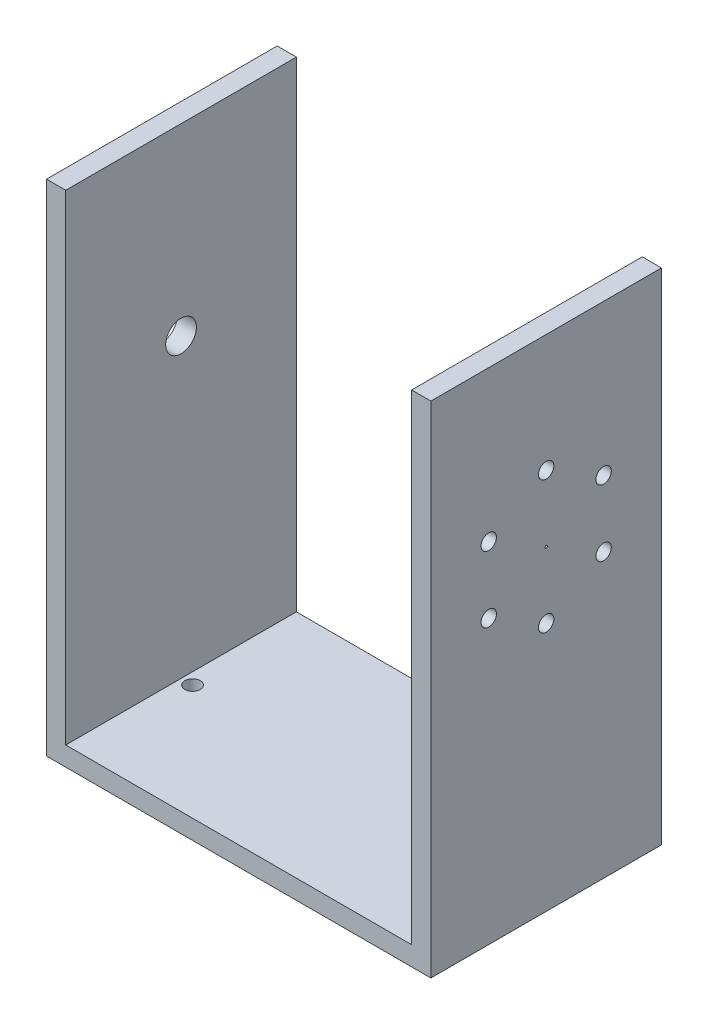
from build123d import *

# Parameters (mm, degrees)
EXTRUDE_1_DEPTH     = 60
SKETCH_2_R          = 2
CUT_EXTRUDE_1_DEPTH = 6
SKETCH_3_R          = 2
SKETCH_3_R_2        = 0.32384185
CUT_EXTRUDE_2_DEPTH = 10
SKETCH_5_R          = 4
SKETCH_5_R_2        = 0.32384185
CUT_EXTRUDE_4_DEPTH = 6


with BuildPart() as part:
    # 草图1 → 凸台-拉伸1 (new body)
    with BuildSketch(Plane.XY):
        Polygon((95, -81.837278389), (95, 48.162721611), (90, 48.162721611), (90, -76.837278389), (0, -76.837278389), (0, 48.162721611), (-5, 48.162721611), (-5, -81.837278389), align=None)
    extrude(amount=EXTRUDE_1_DEPTH)

    # 草图2 → 切除-拉伸1 (cut, through all)
    with BuildSketch(Plane(origin=(0, -76.837278389, 0), x_dir=(1, 0, 0), z_dir=(0, 1, 0))):
        with Locations((3, -30)):
            Circle(SKETCH_2_R)
        with Locations((87, -30)):
            Circle(SKETCH_2_R)
    extrude(amount=-CUT_EXTRUDE_1_DEPTH, mode=Mode.SUBTRACT)

    # 草图3 → 切除-拉伸2 (cut)
    with BuildSketch(Plane.ZY.offset(-90)):
        with Locations((30, 17.582413023)):
            Circle(SKETCH_3_R)
        with Locations((15.060150537, 8.956886914)):
            Circle(SKETCH_3_R)
        with Locations((15.060150537, -8.294165304)):
            Circle(SKETCH_3_R)
        with Locations((30, -16.919691412)):
            Circle(SKETCH_3_R)
        with Locations((44.939849463, -8.294165304)):
            Circle(SKETCH_3_R)
        with Locations((44.939849463, 8.956886914)):
            Circle(SKETCH_3_R)
        with Locations((30, 0.331360805)):
            Circle(SKETCH_3_R_2)
    extrude(amount=-CUT_EXTRUDE_2_DEPTH, mode=Mode.SUBTRACT)

    # 草图5 → 切除-拉伸4 (cut, through all)
    with BuildSketch(Plane(origin=(0, 0, 0), x_dir=(0, 0, -1), z_dir=(1, 0, 0))):
        with Locations((-30, 0.331360805)):
            Circle(SKETCH_5_R)
        with Locations((-30, 0.331360805)):
            Circle(SKETCH_5_R_2, mode=Mode.SUBTRACT)
        with Locations((-30, 0.331360805)):
            Circle(SKETCH_5_R_2)
    extrude(amount=-CUT_EXTRUDE_4_DEPTH, mode=Mode.SUBTRACT)


solid = part.part
